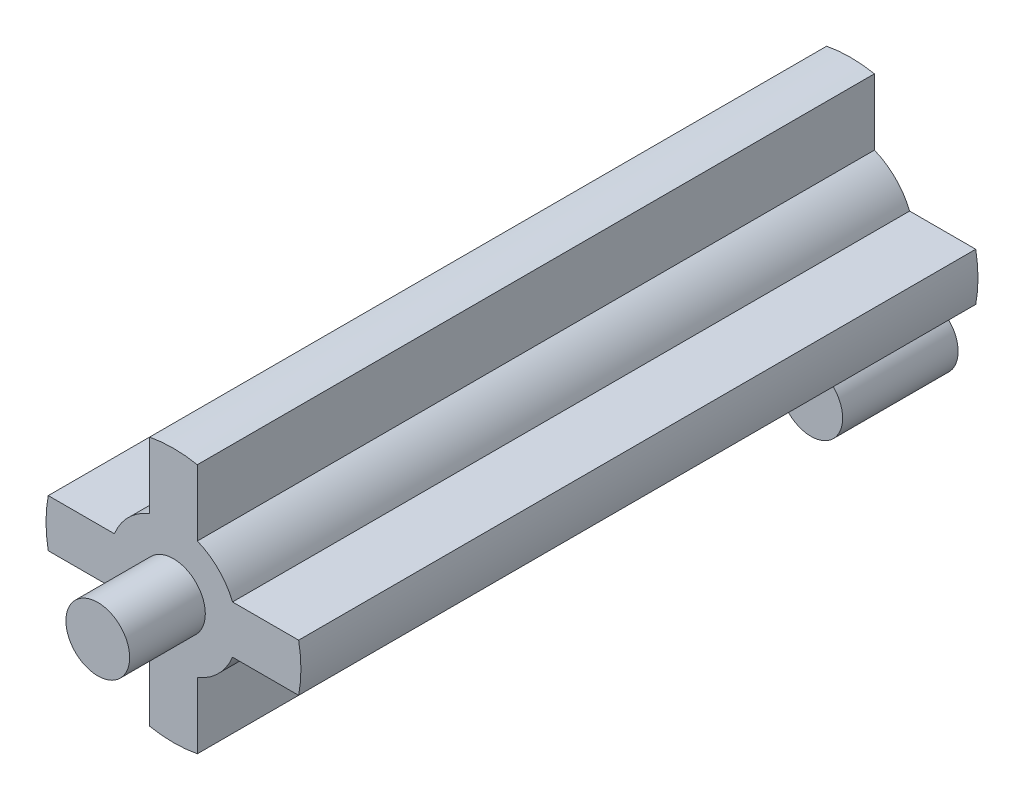
from build123d import *

# Parameters (mm, degrees)
SKETCH1_R           = 16
BOSS_EXTRUDE1_DEPTH = 85
SKETCH3_R           = 4
CUT_EXTRUDE2_DEPTH  = 5
SKETCH4_OUTSIDE_W   = 53.26
SKETCH4_OUTSIDE_H   = 53.26
CUT_EXTRUDE3_DEPTH  = 86
SKETCH5_R           = 3.975
BOSS_EXTRUDE2_DEPTH = 14.5
SKETCH2_R           = 4
BOSS_EXTRUDE3_DEPTH = 9.5


with BuildPart() as part:
    # Sketch1 → Boss-Extrude1 (new body)
    with BuildSketch(Plane.XY):
        Circle(SKETCH1_R)
    extrude(amount=BOSS_EXTRUDE1_DEPTH)

    # Sketch3 → Cut-Extrude2 (cut)
    with BuildSketch(Plane(origin=(0, 0, 0), x_dir=(-1, 0, 0), z_dir=(0, 0, -1))):
        Circle(SKETCH3_R)
    extrude(amount=-CUT_EXTRUDE2_DEPTH, mode=Mode.SUBTRACT)

    # Sketch4 outside → Cut-Extrude3 (cut, through all)
    with BuildSketch(Plane(origin=(0, 0, 0), x_dir=(-1, 0, 0), z_dir=(0, 0, -1))):
        Rectangle(SKETCH4_OUTSIDE_W, SKETCH4_OUTSIDE_H)
        with BuildLine():
            Line((-15.716233646, 3), (-7.416198487, 3))
            ThreePointArc((-7.416198487, 3), (-5.656854249, 5.656854249), (-3, 7.416198487))
            Line((-3, 7.416198487), (-3, 15.716233646))
            ThreePointArc((-3, 15.716233646), (0, 16), (3, 15.716233646))
            Line((3, 15.716233646), (3, 7.416198487))
            ThreePointArc((3, 7.416198487), (5.656854249, 5.656854249), (7.416198487, 3))
            Line((7.416198487, 3), (15.716233646, 3))
            ThreePointArc((15.716233646, 3), (16, 0), (15.716233646, -3))
            Line((15.716233646, -3), (7.416198487, -3))
            ThreePointArc((7.416198487, -3), (5.656854249, -5.656854249), (3, -7.416198487))
            Line((3, -7.416198487), (3, -15.716233646))
            ThreePointArc((3, -15.716233646), (0, -16), (-3, -15.716233646))
            Line((-3, -15.716233646), (-3, -7.416198487))
            ThreePointArc((-3, -7.416198487), (-5.656854249, -5.656854249), (-7.416198487, -3))
            Line((-7.416198487, -3), (-15.716233646, -3))
            ThreePointArc((-15.716233646, -3), (-16, 0), (-15.716233646, 3))
        make_face(mode=Mode.SUBTRACT)
    extrude(amount=-CUT_EXTRUDE3_DEPTH, mode=Mode.SUBTRACT)

    # Sketch2 → Boss-Extrude3 (add)
    with BuildSketch(Plane.XY.offset(85)):
        Circle(SKETCH2_R)
    extrude(amount=BOSS_EXTRUDE3_DEPTH)


with BuildPart() as body_2:
    # Sketch5 → Boss-Extrude2 (new body)
    with BuildSketch(Plane.XY):
        with Locations((9.53294491, -9.218672001)):
            Circle(SKETCH5_R)
    extrude(amount=BOSS_EXTRUDE2_DEPTH)


solid = Compound([part.part, body_2.part])
